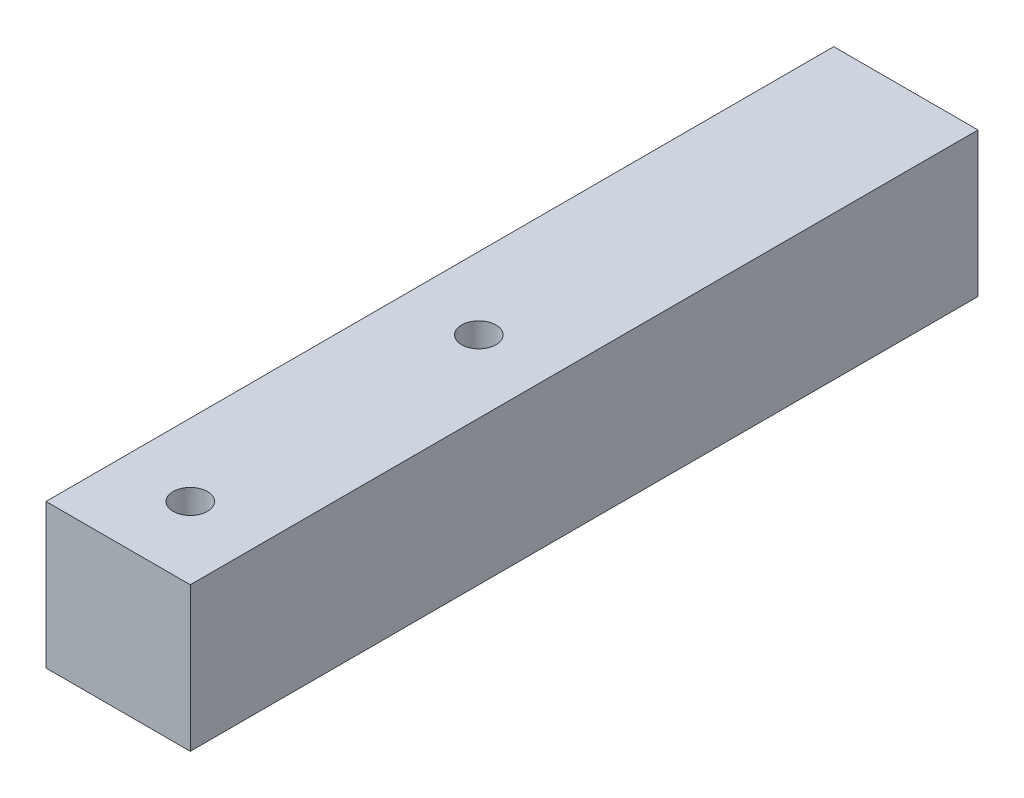
from build123d import *

# Parameters (mm, degrees)
SKETCH1_W                        = 25.4
SKETCH1_H                        = 25.4
BOSS_EXTRUDE1_DEPTH              = 69.341499747
F_6_05_6_05_DIAMETER_HOLE1_D     = 6.05
TAP_DRILL_FOR_M6X0_75_TAP1_D     = 5.25
TAP_DRILL_FOR_M6X0_75_TAP1_DEPTH = 14.732


with BuildPart() as part:
    # Sketch1 → Boss-Extrude1 (new body, symmetric)
    with BuildSketch(Plane.XY):
        Rectangle(SKETCH1_W, SKETCH1_H)
    extrude(amount=BOSS_EXTRUDE1_DEPTH, both=True)

    # Ø6.05 (6.05) Diameter Hole1 (through all)
    with Locations(Plane(origin=(0, -12.7, 0), x_dir=(-1, 0, 0), z_dir=(0, -1, 0))):
        with Locations((0, -5.841499747), (0, -56.641499747)):
            Hole(F_6_05_6_05_DIAMETER_HOLE1_D / 2)

    # Tap Drill for M6x0.75 Tap1
    with Locations(Plane(origin=(0, 0, -69.341499747), x_dir=(-1, 0, 0), z_dir=(0, 0, -1))):
        with Locations((0, 0)):
            Hole(TAP_DRILL_FOR_M6X0_75_TAP1_D / 2, depth=TAP_DRILL_FOR_M6X0_75_TAP1_DEPTH)


solid = part.part
